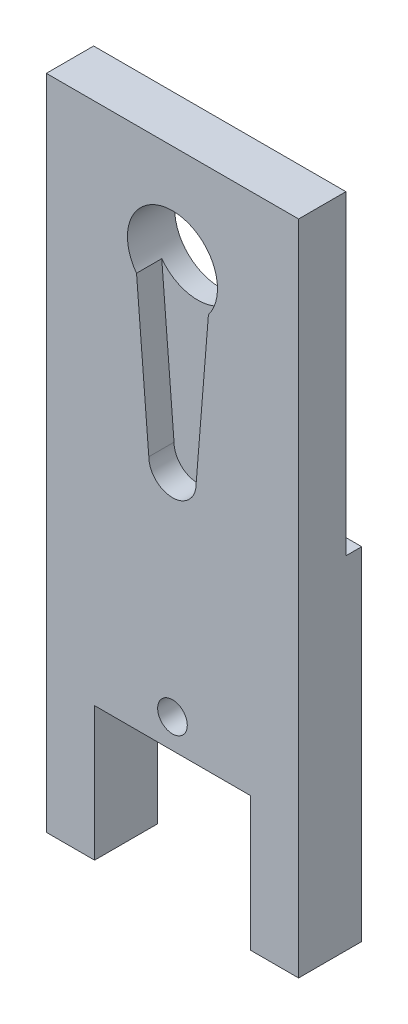
from build123d import *

# Parameters (mm, degrees)
SKETCH3_W           = 20
SKETCH3_H           = 70
BOSS_EXTRUDE3_DEPTH = 5
CUT_EXTRUDE2_DEPTH  = 2
SKETCH6_R           = 3.57
CUT_EXTRUDE3_DEPTH  = 3
SKETCH7_R           = 1.175
SKETCH7_W           = 12.35
SKETCH7_H           = 23
CUT_EXTRUDE4_DEPTH  = 5
SKETCH8_W           = 1.25
SKETCH8_H           = 25
CUT_EXTRUDE5_DEPTH  = 30
SKETCH10_W          = 20
SKETCH10_H          = 17.885322835
CUT_EXTRUDE6_DEPTH  = 10


with BuildPart() as part:
    # Sketch3 → Boss-Extrude3 (new body)
    with BuildSketch(Plane.XY):
        Rectangle(SKETCH3_W, SKETCH3_H)
    extrude(amount=BOSS_EXTRUDE3_DEPTH)

    # Sketch4 → Cut-Extrude2 (cut)
    with BuildSketch(Plane.XY.offset(5)):
        with BuildLine():
            Line((-2.85, 24.850023256), (-1.875, 12.739206809))
            Line((-1.875, 12.739206809), (1.875, 12.739206809))
            Line((1.875, 12.739206809), (2.85, 24.850023256))
            ThreePointArc((2.85, 24.850023256), (0, 23.43), (-2.85, 24.850023256))
        make_face()
        with BuildLine():
            Line((1.875, 12.739206809), (-1.875, 12.739206809))
            ThreePointArc((-1.875, 12.739206809), (0, 10.864206809), (1.875, 12.739206809))
        make_face()
        with BuildLine():
            ThreePointArc((3.57, 27), (-1.133666618, 30.385217866), (-2.85, 24.850023256))
            Line((-2.85, 24.850023256), (2.85, 24.850023256))
            ThreePointArc((2.85, 24.850023256), (3.385217866, 25.866333382), (3.57, 27))
        make_face()
        with BuildLine():
            Line((2.85, 24.850023256), (-2.85, 24.850023256))
            ThreePointArc((-2.85, 24.850023256), (0, 23.43), (2.85, 24.850023256))
        make_face()
    extrude(amount=-CUT_EXTRUDE2_DEPTH, mode=Mode.SUBTRACT)

    # Sketch6 → Cut-Extrude3 (cut)
    with BuildSketch(Plane.XY.offset(3)):
        with Locations((0, 27)):
            Circle(SKETCH6_R)
    extrude(amount=-CUT_EXTRUDE3_DEPTH, mode=Mode.SUBTRACT)

    # Sketch7 → Cut-Extrude4 (cut)
    with BuildSketch(Plane.XY.offset(5)):
        with Locations((0, -4.18)):
            Circle(SKETCH7_R)
        with Locations((0, -31.82)):
            Circle(SKETCH7_R)
        with Locations((0, -18)):
            Rectangle(SKETCH7_W, SKETCH7_H)
    extrude(amount=-CUT_EXTRUDE4_DEPTH, mode=Mode.SUBTRACT)

    # Sketch8 → Cut-Extrude5 (cut)
    with BuildSketch(Plane(origin=(10, 0, 0), x_dir=(0, 0, -1), z_dir=(1, 0, 0))):
        with Locations((-0.625, 22.5)):
            Rectangle(SKETCH8_W, SKETCH8_H)
    extrude(amount=-CUT_EXTRUDE5_DEPTH, mode=Mode.SUBTRACT)

    # Sketch10 → Cut-Extrude6 (cut)
    with BuildSketch(Plane.XY.offset(5)):
        with Locations((0, -26.057338583)):
            Rectangle(SKETCH10_W, SKETCH10_H)
    extrude(amount=-CUT_EXTRUDE6_DEPTH, mode=Mode.SUBTRACT)


solid = part.part
